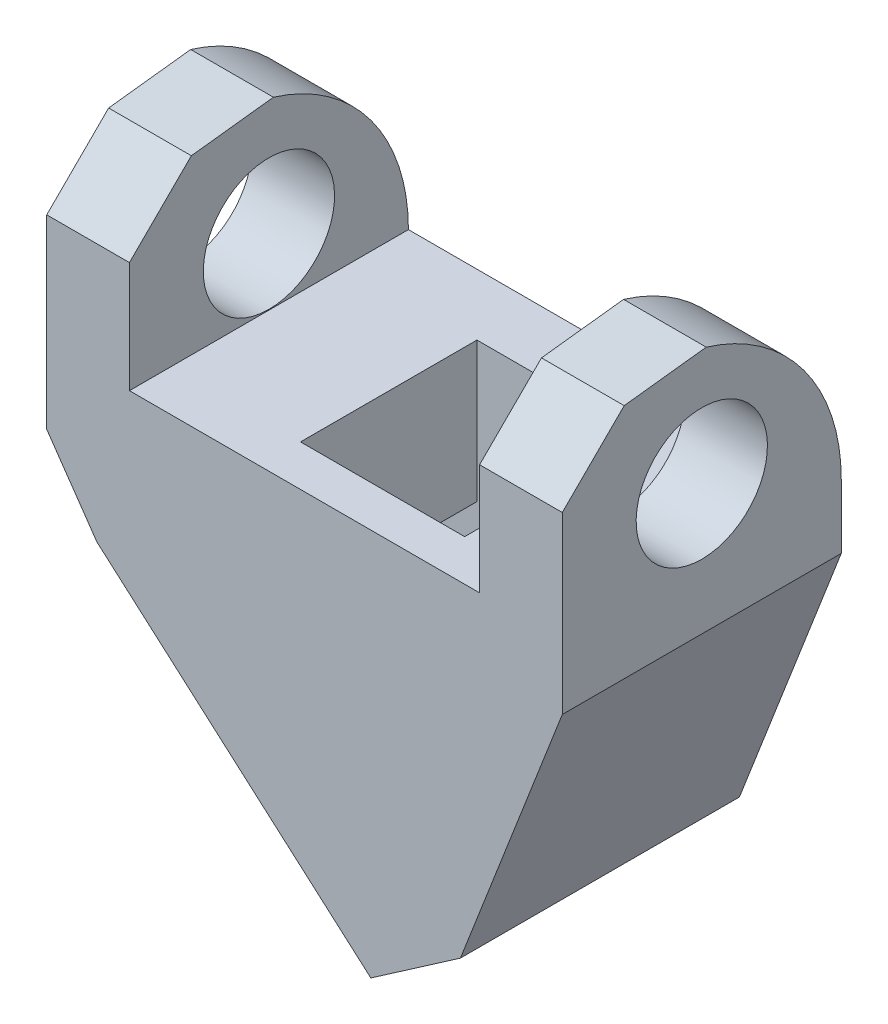
from build123d import *

# Parameters (mm, degrees)
BOSS_EXTRUDE1_DEPTH = 17
CUT_EXTRUDE1_DEPTH  = 31
SKETCH3_W           = 12.47
SKETCH3_H           = 10.75
CUT_EXTRUDE2_REACH  = 25.639
SKETCH6_W           = 10
SKETCH6_H           = 10.75
SKETCH7_R           = 4
CUT_EXTRUDE3_DEPTH  = 31


with BuildPart() as part:
    # Sketch1 → Boss-Extrude1 (new body)
    with BuildSketch(Plane.XY):
        Polygon((0, 0), (0, 11.1), (5.04, 11.1), (5.04, -3.9), (-1.16650456, -19.86), (-6.626200647, -23.639063196), (-23.319289693, -8.973826134), (-26.37555014, -4.558379149), (-26.37555014, 11.1), (-21.33555014, 11.1), (-21.33555014, 0), align=None)
    extrude(amount=BOSS_EXTRUDE1_DEPTH)

    # Sketch2 → Cut-Extrude1 (cut, symmetric)
    with BuildSketch(Plane.ZY):
        Polygon((8.228054067, 11.1), (17, 11.1), (17, 12.88110255), (0, 12.88110255), (0, 11.1), align=None)
        with BuildLine():
            ThreePointArc((0, 0), (2.28131811, 6.908525055), (8.228054067, 11.1))
            Line((8.228054067, 11.1), (0, 11.1))
            Line((0, 11.1), (0, 0))
        make_face()
        Polygon((13.228054067, 10.512247596), (17, 6.76), (17, 11.1), (8.228054067, 11.1), align=None)
    extrude(amount=CUT_EXTRUDE1_DEPTH, both=True, mode=Mode.SUBTRACT)

    # Cut-Sweep1: sweep along a path in Sketch5
    with BuildLine(Plane.XY.offset(7)) as cut_sweep1_path:
        Line((-11.079626433, -19.726633046), (-3.773757644, -14.201247879))
    # Sketch3 → Cut-Sweep1 (sweep, cut)
    with BuildSketch(Plane(origin=(-14.60747623, -16.627341271, 0), x_dir=(-0.751264134, 0.660001668, 0), z_dir=(-0.660001668, -0.751264134, 0))):
        with Locations((-0.368794251, -9.115)):
            Rectangle(SKETCH3_W, SKETCH3_H)
    sweep(path=cut_sweep1_path.line, mode=Mode.SUBTRACT)

    # Cut-Extrude2: up to this face of the body (flat: up to its plane)
    cut_extrude2_end = Plane(part.part.faces().sort_by_distance((-5.99334807, -18.223163907, 9.115))[0])
    # Sketch6 → Cut-Extrude2 (cut, up to the picked face)
    with BuildSketch(Plane(origin=(0, 0, 0), x_dir=(1, 0, 0), z_dir=(0, 1, 0)), mode=Mode.PRIVATE) as cut_extrude2_sk1:
        with Locations((-8.42, -9.115)):
            Rectangle(SKETCH6_W, SKETCH6_H)
    cut_extrude2_tool1 = split(extrude(cut_extrude2_sk1.sketch, amount=-CUT_EXTRUDE2_REACH, mode=Mode.PRIVATE), bisect_by=cut_extrude2_end, keep=Keep.BOTH, mode=Mode.PRIVATE)
    add(cut_extrude2_tool1.solids().sort_by_distance((-8.42, 0, 9.115))[0], mode=Mode.SUBTRACT)

    # Sketch7 → Cut-Extrude3 (cut, symmetric)
    with BuildSketch(Plane.ZY.offset(10.66777507)):
        with Locations((8.5, 4.041620851)):
            Circle(SKETCH7_R)
    extrude(amount=CUT_EXTRUDE3_DEPTH, both=True, mode=Mode.SUBTRACT)


solid = part.part
